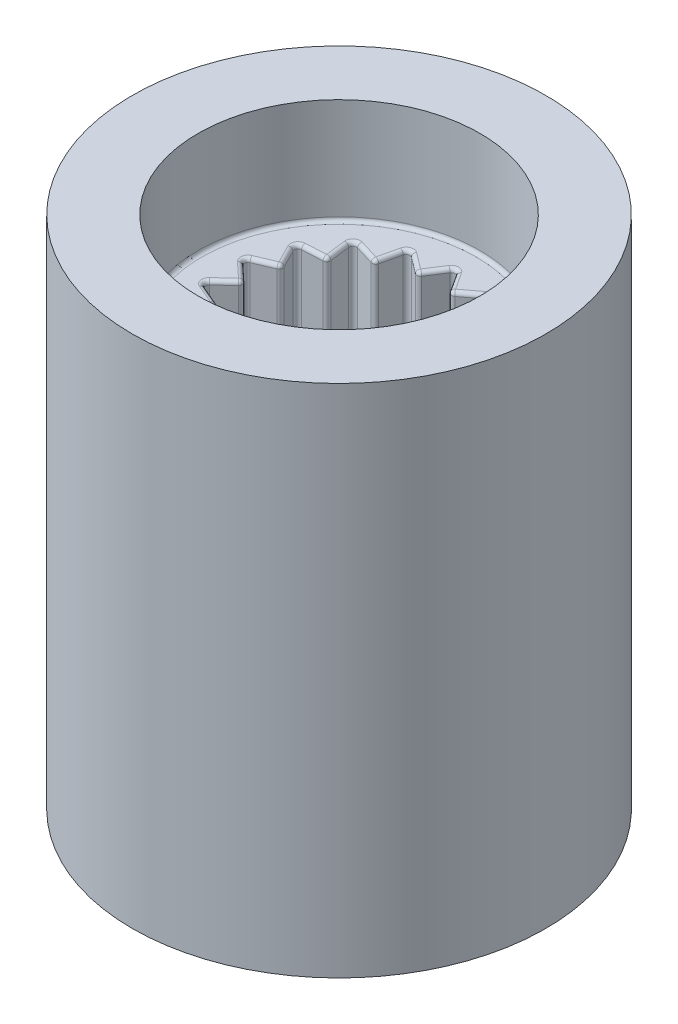
from build123d import *

# Parameters (mm, degrees)
SKETCH2_R           = 5.5
SKETCH2_R_2         = 3.75
BOSS_EXTRUDE1_DEPTH = 13.7
SKETCH3_R           = 4.607658028
BOSS_EXTRUDE2_DEPTH = 10.9
FILLET1_R           = 0.1


with BuildPart() as part:
    # Sketch2 → Boss-Extrude1 (new body)
    with BuildSketch(Plane(origin=(0, 0, 0), x_dir=(1, 0, 0), z_dir=(0, 1, 0))):
        Circle(SKETCH2_R)
        Circle(SKETCH2_R_2, mode=Mode.SUBTRACT)
    extrude(amount=BOSS_EXTRUDE1_DEPTH)

    # Sketch3 → Boss-Extrude2 (add)
    with BuildSketch(Plane(origin=(0, 0, 0), x_dir=(1, 0, 0), z_dir=(0, 1, 0))):
        Circle(SKETCH3_R)
        Polygon((0, 3.167239607), (0.439078531, 2.490138093), (1.083259744, 2.976231687), (1.264276243, 2.189790688), (2.035862376, 2.426246301), (1.936983582, 1.625322209), (2.74290996, 1.583619804), (2.376062113, 0.864815884), (3.119122121, 0.549985386), (2.528552487, 0), (3.119122121, -0.549985386), (2.376062113, -0.864815884), (2.74290996, -1.583619804), (1.936983582, -1.625322209), (2.035862376, -2.426246301), (1.264276243, -2.189790688), (1.083259744, -2.976231687), (0.439078531, -2.490138093), (0, -3.167239607), (-0.439078531, -2.490138093), (-1.083259744, -2.976231687), (-1.264276243, -2.189790688), (-2.035862376, -2.426246301), (-1.936983582, -1.625322209), (-2.74290996, -1.583619804), (-2.376062113, -0.864815884), (-3.119122121, -0.549985386), (-2.528552487, 0), (-3.119122121, 0.549985386), (-2.376062113, 0.864815884), (-2.74290996, 1.583619804), (-1.936983582, 1.625322209), (-2.035862376, 2.426246301), (-1.264276243, 2.189790688), (-1.083259744, 2.976231687), (-0.439078531, 2.490138093), align=None, mode=Mode.SUBTRACT)
    extrude(amount=BOSS_EXTRUDE2_DEPTH)

    # Fillet1
    fillet1_edges = [part.edges().sort_by_distance(p)[0] for p in [
        (-3.75, 10.9, 0),
        (1.986422979, 0, -2.025784255),
        (1.65006931, 0, -2.308018495),
        (1.173767994, 10.9, -2.583011188),
        (1.083259744, 5.45, -2.976231687),
        (1.65006931, 10.9, -2.308018495),
        (1.264276243, 5.45, -2.189790688),
        (1.986422979, 10.9, -2.025784255),
        (2.035862376, 5.45, -2.426246301),
        (2.339946771, 10.9, -1.604471006),
        (1.936983582, 5.45, -1.625322209),
        (2.559486036, 10.9, -1.224217844),
        (2.74290996, 5.45, -1.583619804),
        (2.747592117, 10.9, -0.707400635),
        (2.376062113, 5.45, -0.864815884),
        (2.823837304, 10.9, -0.274992693),
        (3.119122121, 5.45, -0.549985386),
        (2.823837304, 10.9, 0.274992693),
        (2.528552487, 5.45, 0),
        (2.747592117, 10.9, 0.707400635),
        (3.119122121, 5.45, 0.549985386),
        (2.559486036, 10.9, 1.224217844),
        (2.376062113, 5.45, 0.864815884),
        (2.339946771, 10.9, 1.604471006),
        (2.74290996, 5.45, 1.583619804),
        (1.986422979, 10.9, 2.025784255),
        (1.936983582, 5.45, 1.625322209),
        (1.65006931, 10.9, 2.308018495),
        (2.035862376, 5.45, 2.426246301),
        (1.173767994, 10.9, 2.583011188),
        (1.264276243, 5.45, 2.189790688),
        (0.761169138, 10.9, 2.73318489),
        (1.083259744, 5.45, 2.976231687),
        (0.219539266, 10.9, 2.82868885),
        (0.439078531, 5.45, 2.490138093),
        (-0.219539266, 10.9, 2.82868885),
        (0, 5.45, 3.167239607),
        (-0.761169138, 10.9, 2.73318489),
        (-0.439078531, 5.45, 2.490138093),
        (-1.173767994, 10.9, 2.583011188),
        (-1.083259744, 5.45, 2.976231687),
        (-1.65006931, 10.9, 2.308018495),
        (-1.264276243, 5.45, 2.189790688),
        (-1.986422979, 10.9, 2.025784255),
        (-2.035862376, 5.45, 2.426246301),
        (-2.339946771, 10.9, 1.604471006),
        (-1.936983582, 5.45, 1.625322209),
        (-2.559486036, 10.9, 1.224217844),
        (-2.74290996, 5.45, 1.583619804),
        (-2.747592117, 10.9, 0.707400635),
        (-2.376062113, 5.45, 0.864815884),
        (-2.823837304, 10.9, 0.274992693),
        (-3.119122121, 5.45, 0.549985386),
        (-2.823837304, 10.9, -0.274992693),
        (-2.528552487, 5.45, 0),
        (-2.747592117, 10.9, -0.707400635),
        (-3.119122121, 5.45, -0.549985386),
        (-2.559486036, 10.9, -1.224217844),
        (-2.376062113, 5.45, -0.864815884),
        (-2.339946771, 10.9, -1.604471006),
        (-2.74290996, 5.45, -1.583619804),
        (-1.986422979, 10.9, -2.025784255),
        (-1.936983582, 5.45, -1.625322209),
        (-1.65006931, 10.9, -2.308018495),
        (-2.035862376, 5.45, -2.426246301),
        (-1.173767994, 10.9, -2.583011188),
        (-1.264276243, 5.45, -2.189790688),
        (-0.761169138, 10.9, -2.73318489),
        (-1.083259744, 5.45, -2.976231687),
        (-0.219539266, 10.9, -2.82868885),
        (-0.439078531, 5.45, -2.490138093),
        (0.219539266, 10.9, -2.82868885),
        (0, 5.45, -3.167239607),
        (0.761169138, 10.9, -2.73318489),
        (0.439078531, 5.45, -2.490138093),
    ]]
    fillet(fillet1_edges, radius=FILLET1_R)


solid = part.part
